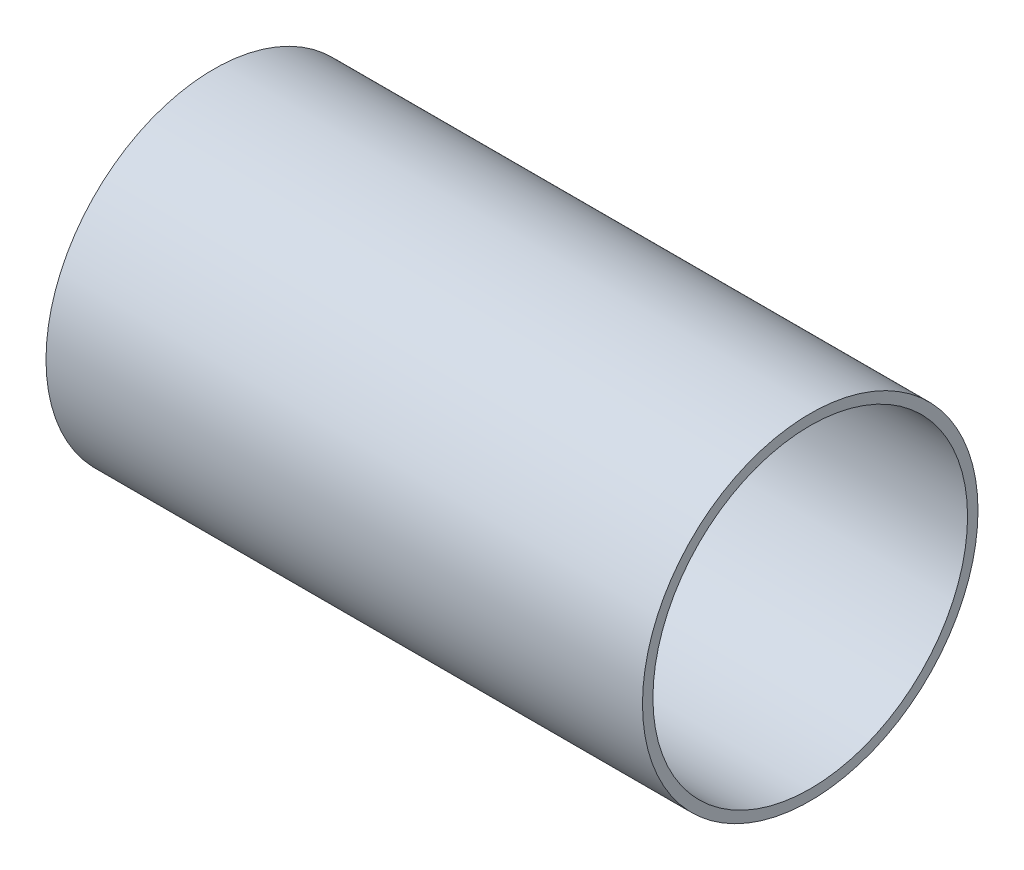
from build123d import *

# Parameters (mm, degrees)
SKETCH1_R      = 14.2875
SKETCH1_R_2    = 13.3985
EXTRUDE1_DEPTH = 25.4


with BuildPart() as part:
    # Sketch1 → Extrude1 (new body, symmetric)
    with BuildSketch(Plane(origin=(0, 0, 0), x_dir=(0, 0, -1), z_dir=(1, 0, 0))):
        Circle(SKETCH1_R)
        Circle(SKETCH1_R_2, mode=Mode.SUBTRACT)
    extrude(amount=EXTRUDE1_DEPTH, both=True)


solid = part.part
